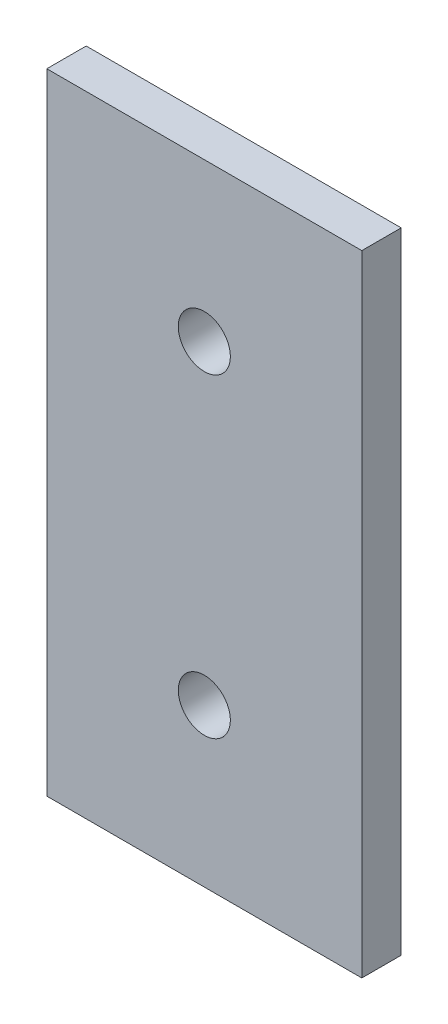
from build123d import *

# Parameters (mm, degrees)
SKETCH1_W           = 25.4
SKETCH1_H           = 50.8
SKETCH1_R           = 2.1
BOSS_EXTRUDE1_DEPTH = 3.175


with BuildPart() as part:
    # Sketch1 → Boss-Extrude1 (new body)
    with BuildSketch(Plane.XY):
        Rectangle(SKETCH1_W, SKETCH1_H)
        with Locations((0, 12.7)):
            Circle(SKETCH1_R, mode=Mode.SUBTRACT)
        with Locations((0, -12.7)):
            Circle(SKETCH1_R, mode=Mode.SUBTRACT)
    extrude(amount=BOSS_EXTRUDE1_DEPTH)


solid = part.part
